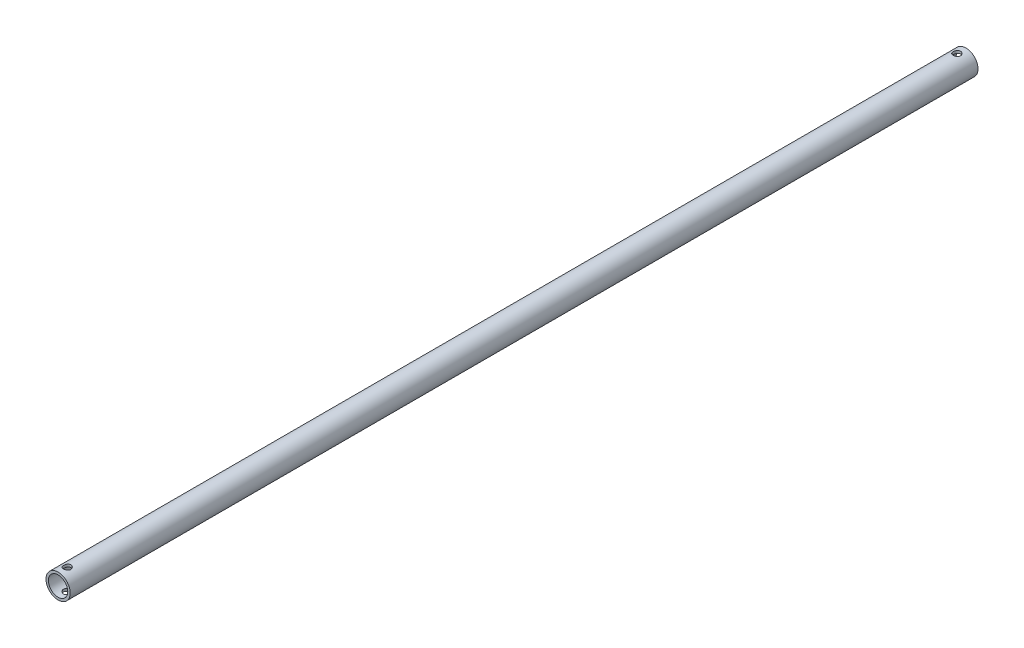
from build123d import *

# Parameters (mm, degrees)
SZKIC1_R                    = 10
DODANIE_WYCI_GNI_CIE2_DEPTH = 750
SZKIC3_R                    = 8
WYTNIJ_WYCI_GNI_CIE1_DEPTH  = 751
SZKIC4_R                    = 3
WYTNIJ_WYCI_GNI_CIE2_DEPTH  = 11


with BuildPart() as part:
    # Szkic1 → Dodanie-wyciągnięcie2 (new body)
    with BuildSketch(Plane.XY):
        Circle(SZKIC1_R)
    extrude(amount=DODANIE_WYCI_GNI_CIE2_DEPTH)

    # Szkic3 → Wytnij-wyciągnięcie1 (cut, through all)
    with BuildSketch(Plane.XY.offset(750)):
        Circle(SZKIC3_R)
    extrude(amount=-WYTNIJ_WYCI_GNI_CIE1_DEPTH, mode=Mode.SUBTRACT)

    # Szkic4 → Wytnij-wyciągnięcie2 (cut, symmetric)
    with BuildSketch(Plane(origin=(0, 0, 0), x_dir=(1, 0, 0), z_dir=(0, 1, 0))):
        with Locations((0, -7.5)):
            Circle(SZKIC4_R)
    wytnij_wyci_gni_cie2 = extrude(amount=WYTNIJ_WYCI_GNI_CIE2_DEPTH, both=True, mode=Mode.SUBTRACT)

    # Mirror1: Wytnij-wyciągnięcie2 across plane
    add(wytnij_wyci_gni_cie2.mirror(Plane.XY.offset(375)), mode=Mode.SUBTRACT)


solid = part.part
